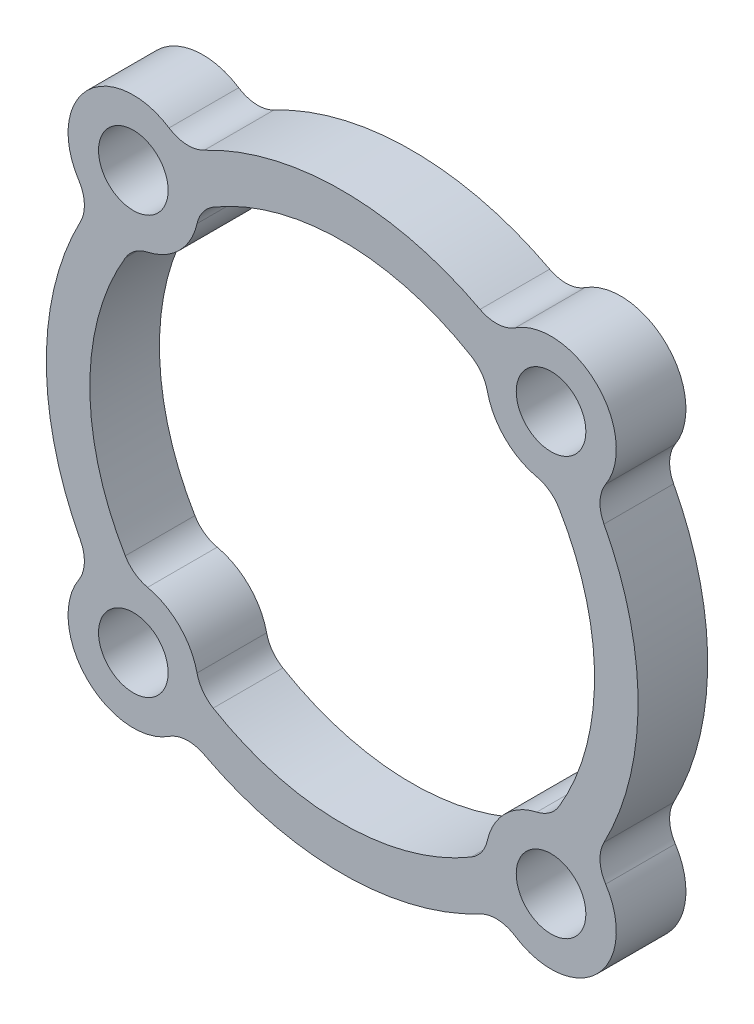
from build123d import *

# Parameters (mm, degrees)
ESQUISSE2_R          = 3.75
BOSS_EXTRU_1_DEPTH   = 4
BOSS_EXTRU_1_2_DEPTH = 4
BOSS_EXTRU_1_3_DEPTH = 4
BOSS_EXTRU_1_4_DEPTH = 4
ESQUISSE3_R          = 17
ESQUISSE3_R_2        = 14.5
BOSS_EXTRU_2_DEPTH   = 4
CONG_1_R             = 2
CONG_2_R             = 2
PER_AGE1_D           = 4
PER_AGE1_DEPTH       = 93.98


with BuildPart() as part:
    # Esquisse2 → Boss.-Extru.1 (new body)
    with BuildSketch(Plane.XY):
        with Locations((-12, 12)):
            Circle(ESQUISSE2_R)
    extrude(amount=BOSS_EXTRU_1_DEPTH)



with BuildPart() as body_2:
    # Esquisse2 → Boss.-Extru.1 2 (new body)
    with BuildSketch(Plane.XY):
        with Locations((12, 12)):
            Circle(ESQUISSE2_R)
    extrude(amount=BOSS_EXTRU_1_2_DEPTH)


with BuildPart() as body_3:
    # Esquisse2 → Boss.-Extru.1 3 (new body)
    with BuildSketch(Plane.XY):
        with Locations((-12, -12)):
            Circle(ESQUISSE2_R)
    extrude(amount=BOSS_EXTRU_1_3_DEPTH)


with BuildPart() as body_4:
    # Esquisse2 → Boss.-Extru.1 4 (new body)
    with BuildSketch(Plane.XY):
        with Locations((12, -12)):
            Circle(ESQUISSE2_R)
    extrude(amount=BOSS_EXTRU_1_4_DEPTH)


with BuildPart() as part_1:
    add(part.part)

    add(body_2.part)  # Boss.-Extru.2 merges body 2

    add(body_3.part)  # Boss.-Extru.2 merges body 3

    add(body_4.part)  # Boss.-Extru.2 merges body 4
    # Esquisse3 → Boss.-Extru.2 (add)
    with BuildSketch(Plane.XY):
        Circle(ESQUISSE3_R)
        Circle(ESQUISSE3_R_2, mode=Mode.SUBTRACT)
    extrude(amount=BOSS_EXTRU_2_DEPTH)

    # Congé1
    cong_1_edges = [part_1.edges().sort_by_distance(p)[0] for p in [
        (-14.365513596, 9.09021557, 2),
        (-9.09021557, 14.365513596, 2),
        (14.365513596, 9.09021557, 2),
        (9.09021557, 14.365513596, 2),
        (-14.365513596, -9.09021557, 2),
        (-9.09021557, -14.365513596, 2),
        (9.09021557, -14.365513596, 2),
        (14.365513596, -9.09021557, 2),
    ]]
    fillet(cong_1_edges, radius=CONG_1_R)

    # Congé2
    cong_2_edges = [part_1.edges().sort_by_distance(p)[0] for p in [
        (-11.92370292, 8.250776246, 2),
        (-8.250776246, 11.92370292, 2),
        (8.250776246, 11.92370292, 2),
        (11.92370292, 8.250776246, 2),
        (-11.92370292, -8.250776246, 2),
        (-8.250776246, -11.92370292, 2),
        (8.250776246, -11.92370292, 2),
        (11.92370292, -8.250776246, 2),
    ]]
    fillet(cong_2_edges, radius=CONG_2_R)

    # Perçage1
    with Locations(Plane(origin=(0, 0, 0), x_dir=(-1, 0, 0), z_dir=(0, 0, -1))):
        with Locations((-12, 12), (12, 12), (12, -12), (-12, -12)):
            Hole(PER_AGE1_D / 2, depth=PER_AGE1_DEPTH)


solid = part_1.part
